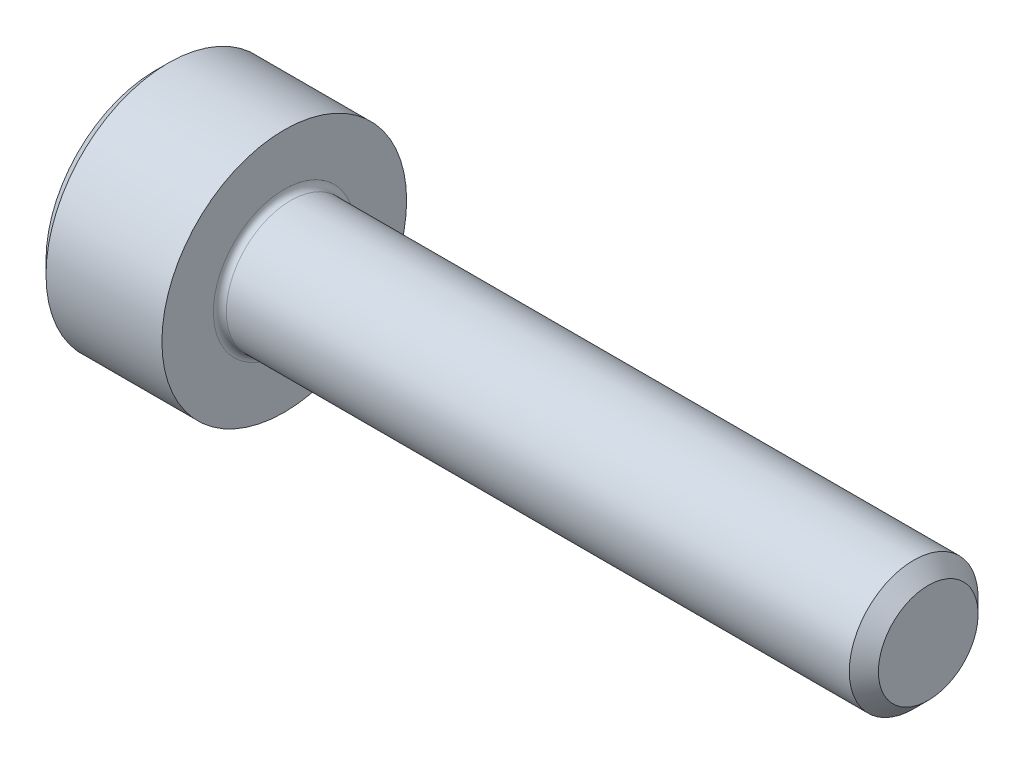
from build123d import *

# Parameters (mm, degrees)
FILLET1_R   = 0.1
HEX_2_DEPTH = 1


with BuildPart() as part:
    # BodySke → Base-Revolve (revolve)
    with BuildSketch(Plane.XY):
        Polygon((0, 0), (0, 1.7), (0.2, 1.9), (2, 1.9), (2, 1), (11.774, 1), (12, 0.774), (12, 0), align=None)
    revolve(axis=Axis((-31.75, 0, 0), (1, 0, 0)))

    # Fillet1
    fillet1_edges = [part.edges().sort_by_distance(p)[0] for p in [
        (2, -1, 0),
    ]]
    fillet(fillet1_edges, radius=FILLET1_R)

    # Sketch2 → Hex-PreBroach (revolve, cut)
    with BuildSketch(Plane.XY):
        Polygon((0, 0.7725), (1, 0.7725), (1.446003083, 0), (0, 0), align=None)
    revolve(axis=Axis((0, 0, 0), (1, 0, 0)), mode=Mode.SUBTRACT)

    # Sketch3 → Hex 2 (cut)
    with BuildSketch(Plane(origin=(0, 0, 0), x_dir=(0, 0.5, 0.866025404), z_dir=(-1, 0, 0))):
        Polygon((0.446003083, 0.7725), (-0.446003083, 0.7725), (-0.892006166, 0), (-0.446003083, -0.7725), (0.446003083, -0.7725), (0.892006166, 0), align=None)
    extrude(amount=-HEX_2_DEPTH, mode=Mode.SUBTRACT)


solid = part.part
